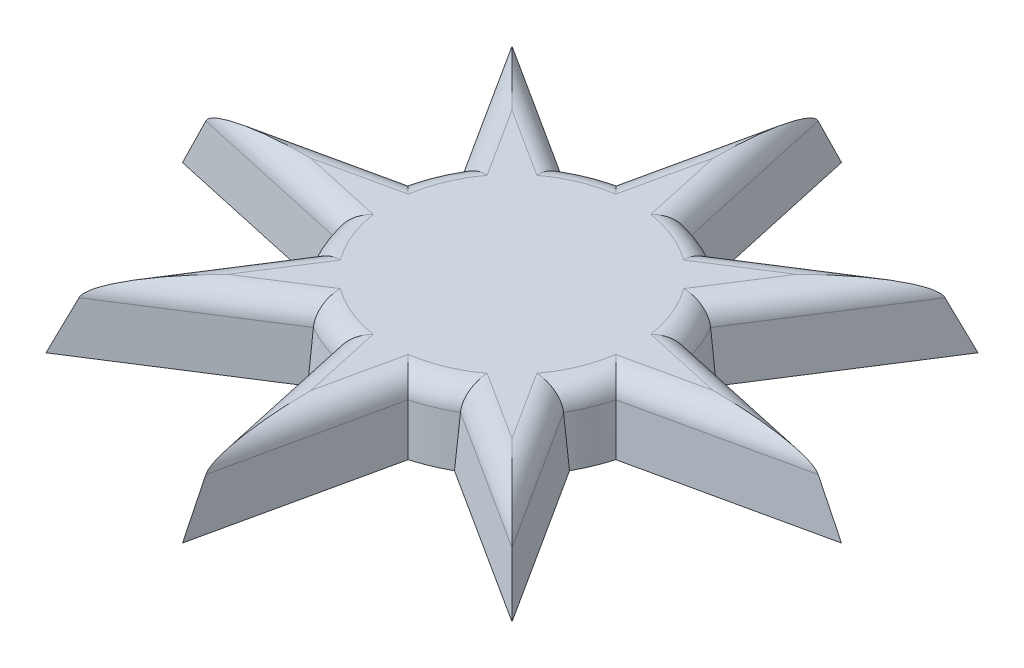
from build123d import *

# Parameters (mm, degrees)
BOSS_EXTRUDE1_DEPTH = 3
BOSS_EXTRUDE1_TAPER = 6
FILLET1_R           = 1


with BuildPart() as part:
    # Sketch2 → Boss-Extrude1 (new body)
    with BuildSketch(Plane(origin=(0, 0, 0), x_dir=(1, 0, 0), z_dir=(0, 1, 0))):
        with BuildLine():
            Line((1.794958228, 6.376825284), (0, 14.54359673))
            Line((0, 14.54359673), (-1.794958228, 6.376825284))
            ThreePointArc((-1.794958228, 6.376825284), (-2.535137681, 6.120363771), (-3.239869266, 5.778323536))
            Line((-3.239869266, 5.778323536), (-10.283875871, 10.283875871))
            Line((-10.283875871, 10.283875871), (-5.778323536, 3.239869266))
            ThreePointArc((-5.778323536, 3.239869266), (-6.120363771, 2.535137681), (-6.376825284, 1.794958228))
            Line((-6.376825284, 1.794958228), (-14.54359673, 0))
            Line((-14.54359673, 0), (-6.376825284, -1.794958228))
            ThreePointArc((-6.376825284, -1.794958228), (-6.120363771, -2.535137681), (-5.778323536, -3.239869266))
            Line((-5.778323536, -3.239869266), (-10.283875871, -10.283875871))
            Line((-10.283875871, -10.283875871), (-3.239869266, -5.778323536))
            ThreePointArc((-3.239869266, -5.778323536), (-2.535137681, -6.120363771), (-1.794958228, -6.376825284))
            Line((-1.794958228, -6.376825284), (0, -14.54359673))
            Line((0, -14.54359673), (1.794958228, -6.376825284))
            ThreePointArc((1.794958228, -6.376825284), (2.535137681, -6.120363771), (3.239869266, -5.778323536))
            Line((3.239869266, -5.778323536), (10.283875871, -10.283875871))
            Line((10.283875871, -10.283875871), (5.778323536, -3.239869266))
            ThreePointArc((5.778323536, -3.239869266), (6.120363771, -2.535137681), (6.376825284, -1.794958228))
            Line((6.376825284, -1.794958228), (14.54359673, 0))
            Line((14.54359673, 0), (6.376825284, 1.794958228))
            ThreePointArc((6.376825284, 1.794958228), (6.120363771, 2.535137681), (5.778323536, 3.239869266))
            Line((5.778323536, 3.239869266), (10.283875871, 10.283875871))
            Line((10.283875871, 10.283875871), (3.239869266, 5.778323536))
            ThreePointArc((3.239869266, 5.778323536), (2.535137681, 6.120363771), (1.794958228, 6.376825284))
        make_face()
    extrude(amount=BOSS_EXTRUDE1_DEPTH, taper=BOSS_EXTRUDE1_TAPER)

    # Fillet1
    fillet1_edges = [part.edges().sort_by_distance(p)[0] for p in [
        (-9.598084382, 3, -0.764125431),
        (-5.829052816, 3, -2.414472732),
        (-7.327188827, 3, -6.246552279),
        (-6.246552279, 3, -7.327188827),
        (-2.414472732, 3, -5.829052816),
        (-0.764125431, 3, -9.598084382),
        (0.764125431, 3, -9.598084382),
        (2.414472732, 3, -5.829052816),
        (6.246552279, 3, -7.327188827),
        (7.327188827, 3, -6.246552279),
        (5.829052816, 3, -2.414472732),
        (9.598084382, 3, -0.764125431),
        (9.598084382, 3, 0.764125431),
        (5.829052816, 3, 2.414472732),
        (7.327188827, 3, 6.246552279),
        (6.246552279, 3, 7.327188827),
        (2.414472732, 3, 5.829052816),
        (0.764125431, 3, 9.598084382),
        (-0.764125431, 3, 9.598084382),
        (-2.414472732, 3, 5.829052816),
        (-6.246552279, 3, 7.327188827),
        (-7.327188827, 3, 6.246552279),
        (-5.829052816, 3, 2.414472732),
        (-9.598084382, 3, 0.764125431),
    ]]
    fillet(fillet1_edges, radius=FILLET1_R)


solid = part.part
